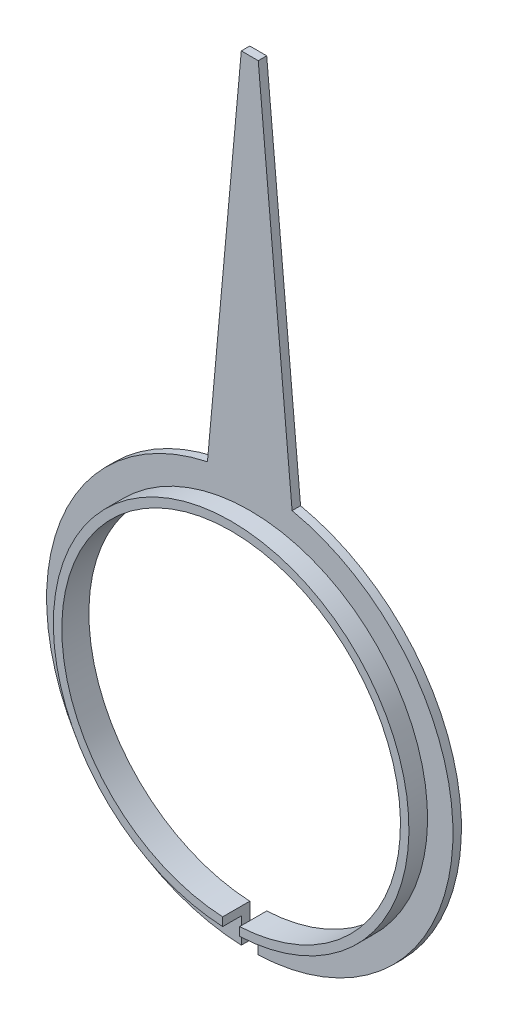
from build123d import *

# Parameters (mm, degrees)
BOSS_EXTRUDE1_DEPTH = 0.1
SKETCH3_R           = 2.1
BOSS_EXTRUDE2_DEPTH = 0.32
SKETCH4_R           = 2
CUT_EXTRUDE1_DEPTH  = 1.32
SKETCH5_W           = 0.2
SKETCH5_H           = 0.897152977
CUT_EXTRUDE2_DEPTH  = 1.32


with BuildPart() as part:
    # Sketch1 → Boss-Extrude1 (new body)
    with BuildSketch(Plane.XY):
        with BuildLine():
            Line((0, 6.75), (0.1, 6.75))
            Line((0.1, 6.75), (0.5, 2.347338919))
            ThreePointArc((0.5, 2.347338919), (0, -2.4), (-0.5, 2.347338919))
            Line((-0.5, 2.347338919), (-0.1, 6.75))
            Line((-0.1, 6.75), (0, 6.75))
        make_face()
    extrude(amount=BOSS_EXTRUDE1_DEPTH)

    # Sketch3 → Boss-Extrude2 (add)
    with BuildSketch(Plane.XY):
        Circle(SKETCH3_R)
    extrude(amount=BOSS_EXTRUDE2_DEPTH)

    # Sketch4 → Cut-Extrude1 (cut, through all)
    with BuildSketch(Plane.XY):
        Circle(SKETCH4_R)
    extrude(amount=CUT_EXTRUDE1_DEPTH, mode=Mode.SUBTRACT)

    # Sketch5 → Cut-Extrude2 (cut, through all)
    with BuildSketch(Plane.XY):
        with Locations((0, -2.259612308)):
            Rectangle(SKETCH5_W, SKETCH5_H)
    extrude(amount=CUT_EXTRUDE2_DEPTH, mode=Mode.SUBTRACT)


solid = part.part
